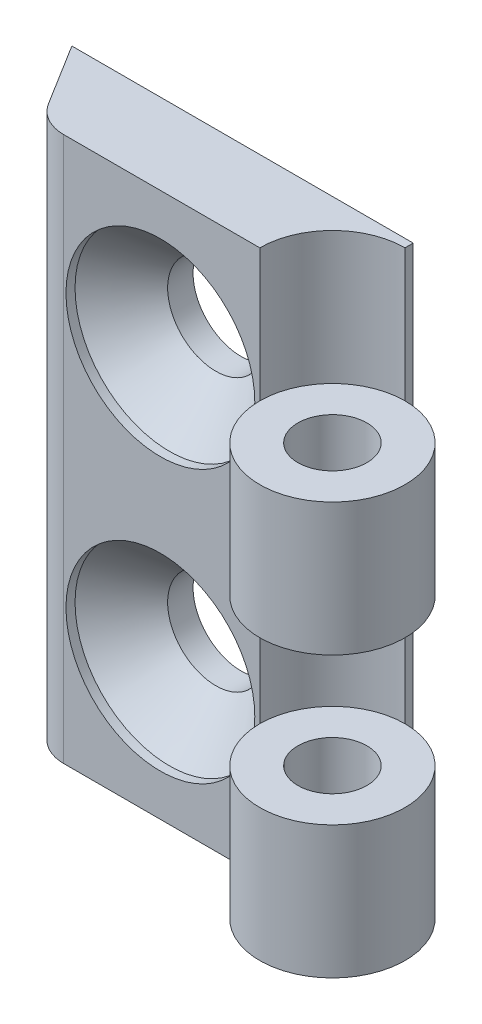
from build123d import *

# Parameters (mm, degrees)
SKETCH1_R                                    = 1.9
BOSS_EXTRUDE1_DEPTH                          = 7.3
BOSS_EXTRUDE2_DEPTH                          = 30
BOSS_EXTRUDE5_START                          = 15.4
SKETCH1_7_R                                  = 1.9
BOSS_EXTRUDE5_DEPTH                          = 7.3
CSK_FOR_M5_COUNTERSUNK_FLAT_HEAD_SCR_2_COUNT = 2
CSK_FOR_M5_COUNTERSUNK_FLAT_HEAD_SCR_2_PITCH = 15


with BuildPart() as part:
    # Sketch1 → Boss-Extrude1 (new body)
    with BuildSketch(Plane(origin=(0, 0, 0), x_dir=(1, 0, 0), z_dir=(0, 1, 0))):
        with BuildLine():
            Line((0, 4), (0, 4.45))
            Line((0, 4.45), (-18.8, 4.45))
            Line((-18.8, 4.45), (-16.690397065, 1.051533367))
            ThreePointArc((-16.690397065, 1.051533367), (-15.8815872, 0.280573573), (-14.8, 0))
            Line((-14.8, 0), (-4, 0))
            ThreePointArc((-4, 0), (2.828427125, -2.828427125), (0, 4))
        make_face()
        Circle(SKETCH1_R, mode=Mode.SUBTRACT)
    extrude(amount=BOSS_EXTRUDE1_DEPTH)

    # Sketch1_3 → Boss-Extrude2 (add)
    with BuildSketch(Plane(origin=(0, 0, 0), x_dir=(1, 0, 0), z_dir=(0, 1, 0))):
        with BuildLine():
            Line((0, 4), (0, 4.45))
            Line((0, 4.45), (-18.8, 4.45))
            Line((-18.8, 4.45), (-16.690397065, 1.051533367))
            ThreePointArc((-16.690397065, 1.051533367), (-15.8815872, 0.280573573), (-14.8, 0))
            Line((-14.8, 0), (-4, 0))
            ThreePointArc((-4, 0), (-2.828427125, 2.828427125), (0, 4))
        make_face()
    extrude(amount=BOSS_EXTRUDE2_DEPTH)

    # Sketch1_7 → Boss-Extrude5 (add)
    with BuildSketch(Plane(origin=(0, 0, 0), x_dir=(1, 0, 0), z_dir=(0, 1, 0)).offset(BOSS_EXTRUDE5_START)):
        with BuildLine():
            ThreePointArc((4, 0), (2.828427125, 2.828427125), (0, 4))
            ThreePointArc((0, 4), (-2.828427125, 2.828427125), (-4, 0))
            ThreePointArc((-4, 0), (0, -4), (4, 0))
        make_face()
        Circle(SKETCH1_7_R, mode=Mode.SUBTRACT)
    extrude(amount=BOSS_EXTRUDE5_DEPTH)

    # Sketch3 → CSK for M5 Countersunk Flat Head Screw1 (revolve, cut)
    with BuildSketch(Plane(origin=(-9.475, 22.5, 0), x_dir=(0, -1, 0), z_dir=(1, 0, 0))):
        Polygon((0, 0), (0, 4.45), (2.65, 4.45), (2.65, 3.05), (5.2, 0.5), (5.2, 0), align=None)
    csk_for_m5_countersunk_flat_head_screw1 = revolve(axis=Axis((-9.475, 22.5, 6.35), (0, 0, -1)), mode=Mode.SUBTRACT)

    # CSK for M5 Countersunk Flat Head Scr 2: CSK for M5 Countersunk Flat Head Screw1 ×2
    with Locations(*[(0, -i * CSK_FOR_M5_COUNTERSUNK_FLAT_HEAD_SCR_2_PITCH, 0) for i in range(1, CSK_FOR_M5_COUNTERSUNK_FLAT_HEAD_SCR_2_COUNT)]):
        add(csk_for_m5_countersunk_flat_head_screw1, mode=Mode.SUBTRACT)


solid = part.part
